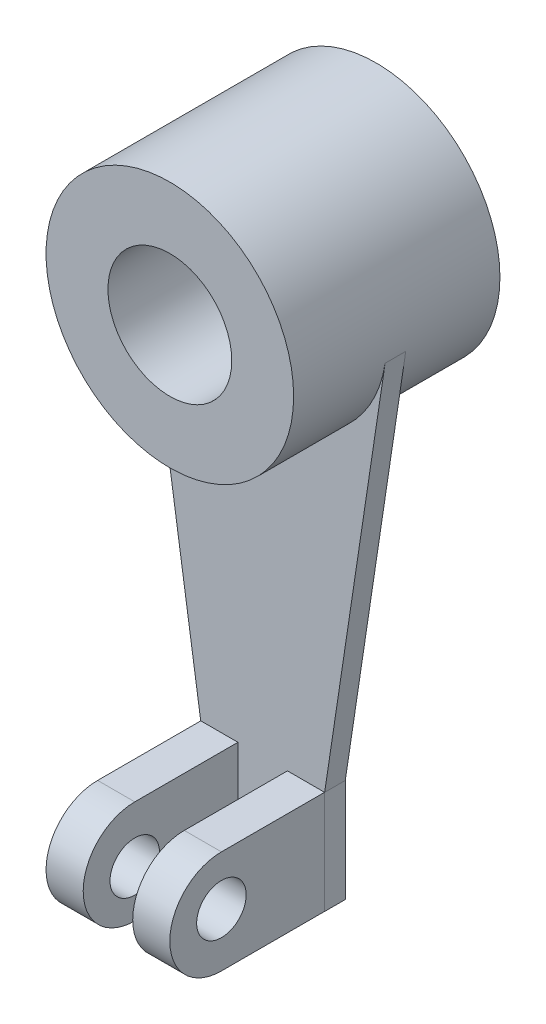
from build123d import *

# Parameters (mm, degrees)
SKETCH1_R                   = 30
BOSS_EXTRUDE1_DEPTH         = 25
SKETCH2_R                   = 15
CUT_EXTRUDE1_DEPTH          = 50
BOSS_EXTRUDE2_DEPTH         = 2.5
BOSS_EXTRUDE5_DEPTH         = 9
F_12_0MM_DOWEL_HOLE2_D      = 12
F_12_0MM_DOWEL_HOLE4_REACH  = 47
F_12_0MM_DOWEL_HOLE4_BORE_R = 6


with BuildPart() as part:
    # Sketch1 → Boss-Extrude1 (new body, symmetric)
    with BuildSketch(Plane.XY):
        Circle(SKETCH1_R)
    extrude(amount=BOSS_EXTRUDE1_DEPTH, both=True)

    # Sketch2 → Cut-Extrude1 (cut)
    with BuildSketch(Plane.XY.offset(25)):
        Circle(SKETCH2_R)
    extrude(amount=-CUT_EXTRUDE1_DEPTH, mode=Mode.SUBTRACT)

    # Sketch5 → Boss-Extrude2 (add, symmetric)
    with BuildSketch(Plane.XY):
        with BuildLine():
            Line((0, -126.848781463), (15, -126.848781463))
            Line((15, -126.848781463), (15, -101.848781463))
            Line((15, -101.848781463), (29.665480102, -4.467582154))
            ThreePointArc((29.665480102, -4.467582154), (-0.002940824, -29.999999856), (-29.666355424, -4.461766004))
            Line((-29.666355424, -4.461766004), (-15.019093199, -101.851653046))
            Line((-15.019093199, -101.851653046), (-15.019093199, -126.848781463))
            Line((-15.019093199, -126.848781463), (0, -126.848781463))
        make_face()
    boss_extrude2 = extrude(amount=BOSS_EXTRUDE2_DEPTH, both=True)

    # Sketch7 → Boss-Extrude5 (add)
    with BuildSketch(Plane(origin=(15, 0, 0), x_dir=(0, 0, -1), z_dir=(1, 0, 0))):
        with BuildLine():
            Line((-2.5, -101.848781463), (-27.5, -101.848781463))
            ThreePointArc((-27.5, -101.848781463), (-40, -114.348781463), (-27.5, -126.848781463))
            Line((-27.5, -126.848781463), (-2.5, -126.848781463))
            Line((-2.5, -126.848781463), (-2.5, -101.848781463))
        make_face()
    boss_extrude5 = extrude(amount=-BOSS_EXTRUDE5_DEPTH)

    # Ø12.0mm Dowel Hole2 (through all)
    with Locations(Plane(origin=(15, 0, 0), x_dir=(0, 0, -1), z_dir=(1, 0, 0))):
        with Locations((-27.5, -113.848781463)):
            Hole(F_12_0MM_DOWEL_HOLE2_D / 2)

    # Mirror1: Boss-Extrude2, Boss-Extrude5 across plane
    add(boss_extrude2.mirror(Plane(origin=(0, 0, 0), x_dir=(0, 0, 1), z_dir=(1, 0, 0))))
    add(boss_extrude5.mirror(Plane(origin=(0, 0, 0), x_dir=(0, 0, 1), z_dir=(1, 0, 0))))

    # Ø12.0mm Dowel Hole4 bore → Ø12.0mm Dowel Hole4 (cut, up to next)
    with BuildSketch(Plane.ZY.offset(15), mode=Mode.PRIVATE) as f_12_0mm_dowel_hole4_sk1:
        with Locations((27.5, -115.421061469)):
            Circle(F_12_0MM_DOWEL_HOLE4_BORE_R)
    f_12_0mm_dowel_hole4_tool1 = extrude(f_12_0mm_dowel_hole4_sk1.sketch, amount=-F_12_0MM_DOWEL_HOLE4_REACH, mode=Mode.PRIVATE) & part.part
    add(f_12_0mm_dowel_hole4_tool1.solids().sort_by_distance((-15, -115.421061, 27.5))[0], mode=Mode.SUBTRACT)


solid = part.part
